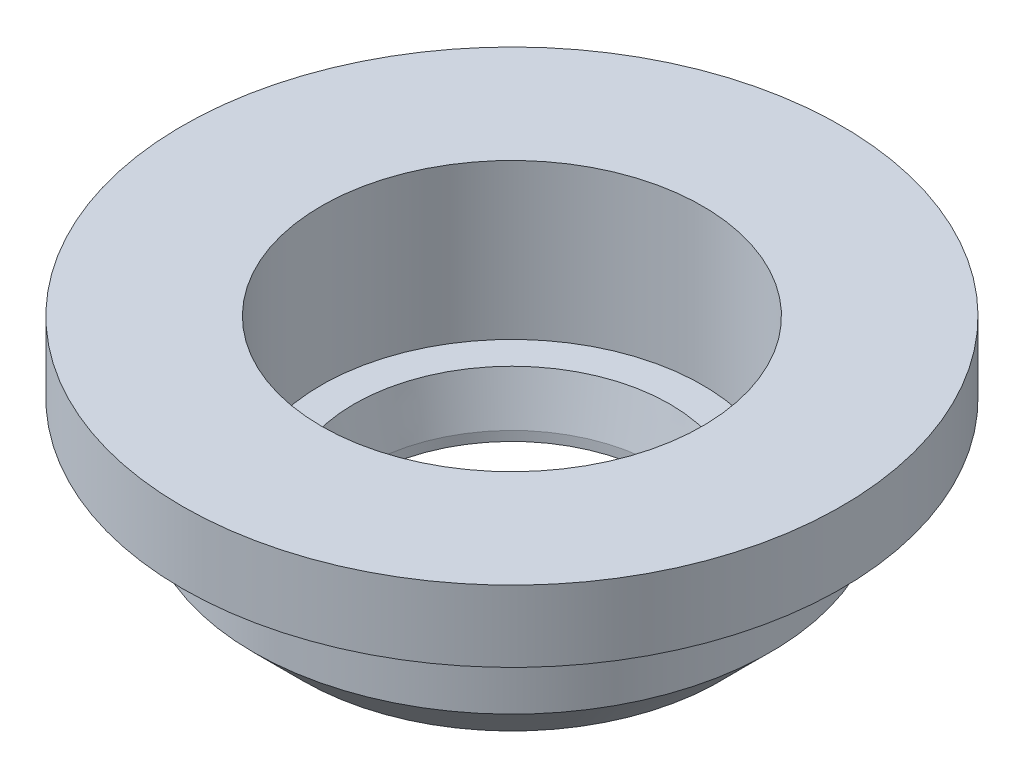
from build123d import *


with BuildPart() as part:
    # Sketch1 → Revolve1 (revolve)
    with BuildSketch(Plane.XY):
        Polygon((9.2075, 4.292270422), (9.2075, 7.530770422), (11.7475, 7.530770422), (11.7475, 10.070770422), (8.89, 10.070770422), (6.7945, 10.070770422), (6.7945, 5.308270422), (6.7945, 4.546270422), (5.624370085, 4.546270422), (5.213993169, 2.85494809), (5.213993169, 2.514270422), (7.4295, 2.514270422), align=None)
    revolve(axis=Axis((0, 10.448595422, 0), (0, -1, 0)))


solid = part.part
